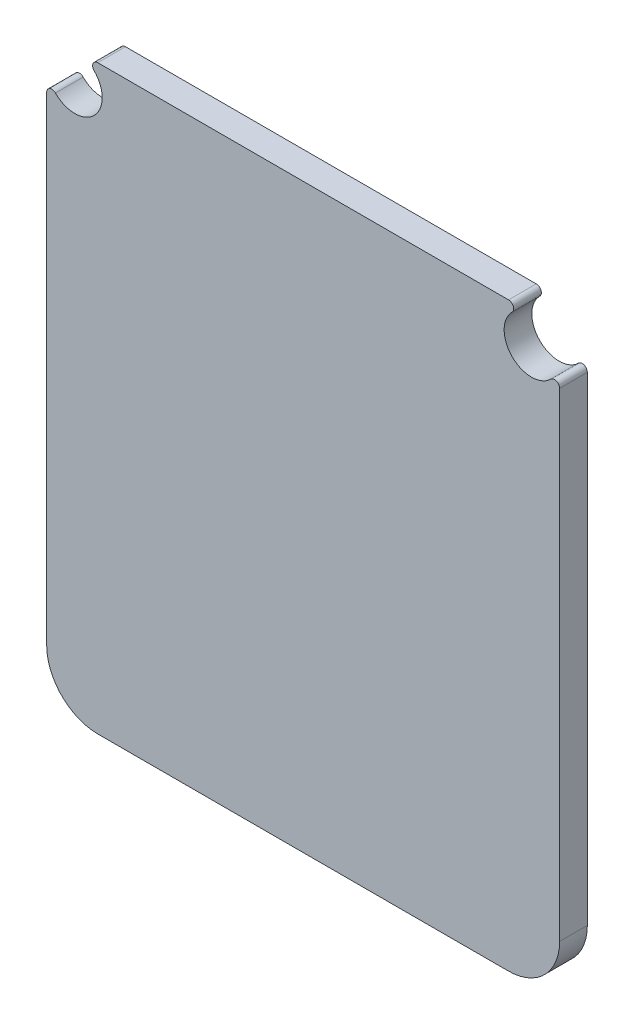
from build123d import *

# Parameters (mm, degrees)
BOARD_DEPTH = 1.6194


with BuildPart() as part:
    # Sketch1 → Board (new body)
    with BuildSketch(Plane.XY):
        with BuildLine():
            Line((10, 29), (10, 57.01299))
            ThreePointArc((10, 57.01299), (10.185190901, 57.290158106), (10.51213, 57.22513))
            ThreePointArc((10.51213, 57.22513), (12.777621512, 57.222368475), (12.77487, 59.48786))
            ThreePointArc((12.77487, 59.48786), (12.709829188, 59.814802566), (12.987, 60))
            Line((12.987, 60), (37.01299, 60))
            ThreePointArc((37.01299, 60), (37.290150019, 59.814804479), (37.22512, 59.48787))
            ThreePointArc((37.22512, 59.48787), (37.223732391, 57.223742391), (39.48786, 57.22513))
            ThreePointArc((39.48786, 57.22513), (39.814807186, 57.290168899), (40, 57.01299))
            Line((40, 57.01299), (40, 29))
            ThreePointArc((40, 29), (39.121323273, 26.878676727), (37, 26))
            Line((37, 26), (13, 26))
            ThreePointArc((13, 26), (10.878679656, 26.878679656), (10, 29))
        make_face()
    extrude(amount=BOARD_DEPTH)


solid = part.part
